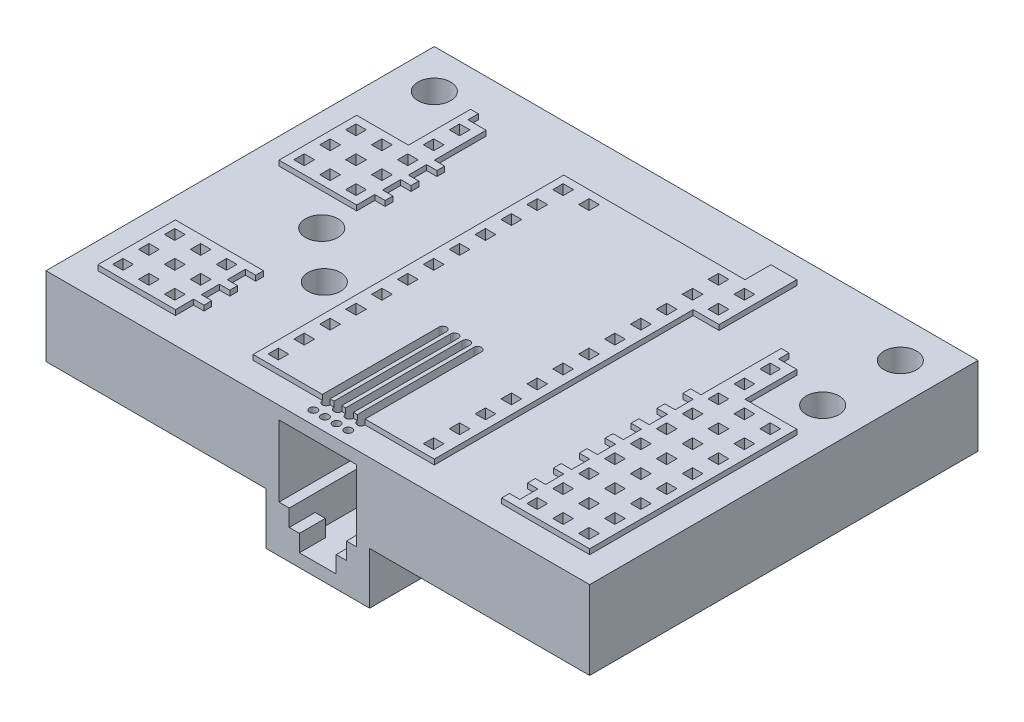
from build123d import *

# Parameters (mm, degrees)
SKETCH1_W             = 53.34
SKETCH1_H             = 38.1
SKETCH1_R             = 1.599999975
BREADBOARD_DEPTH      = 8.2296
SKETCH7_W             = 12.7
SKETCH7_H             = 2.032
CUT_EXTRUDE5_DEPTH    = 7.1628
LPATTERN4_COUNT       = 10
LPATTERN4_PITCH       = 2.54
LPATTERN4_COUNT_DIR2  = 2
LPATTERN4_PITCH_DIR2  = 25.4
SKETCH8_W             = 2.032
SKETCH8_H             = 12.7
CUT_EXTRUDE6_DEPTH    = 7.1628
LPATTERN5_COUNT       = 2
LPATTERN5_PITCH       = 12.7
LPATTERN5_COUNT_DIR2  = 2
LPATTERN5_PITCH_DIR2  = 2.54
SKETCH9_W             = 1.905
SKETCH9_H             = 20.32
CUT_EXTRUDE7_DEPTH    = 7.1628
LPATTERN6_COUNT       = 2
LPATTERN6_PITCH       = 2.54
SKETCH10_W            = 1.016
SKETCH10_H            = 1.016
CUT_EXTRUDE8_DEPTH    = 34.548429231
LPATTERN8_COUNT       = 12
LPATTERN8_PITCH       = 2.54
LPATTERN8_COUNT_DIR2  = 19
LPATTERN8_PITCH_DIR2  = 2.54
SKETCH12_W            = 12.7
SKETCH12_H            = 2.032
CUT_EXTRUDE9_DEPTH    = 7.1628
LPATTERN9_COUNT       = 2
LPATTERN9_PITCH       = 2.54
SKETCH47_W            = 10.16
SKETCH47_H            = 12.7
BOSS_EXTRUDE5_DEPTH   = 5.08
CUT_EXTRUDE33_DEPTH   = 10.9982
SKETCH57_W            = 5.6134
SKETCH57_H            = 9.7282
CUT_EXTRUDE34_DEPTH   = 1.651
SKETCH59_W            = 0.762
SKETCH59_H            = 4.064
CUT_EXTRUDE35_DEPTH   = 5.08
LPATTERN25_COUNT      = 4
LPATTERN25_PITCH      = 1.143
SKETCH62_R            = 0.381
CUT_EXTRUDE37_DEPTH   = 7.62
LPATTERN27_COUNT      = 4
LPATTERN27_PITCH      = 1.143
LPATTERN27_COUNT_DIR2 = 2
LPATTERN27_PITCH_DIR2 = 12.7
CUT_EXTRUDE38_DEPTH   = 1.27
LPATTERN28_COUNT      = 4
LPATTERN28_PITCH      = 1.143
SKETCH66_W            = 5.6134
SKETCH66_H            = 3.175
CUT_EXTRUDE41_DEPTH   = 0.508
SKETCH68_W            = 5.08
SKETCH68_H            = 2.032
CUT_EXTRUDE43_DEPTH   = 7.1628
TRACING_DEPTH         = 1.5748
SKETCH80_W            = 5.08
SKETCH80_H            = 2.032
CUT_EXTRUDE52_DEPTH   = 7.1628
SKETCH77_W            = 2.032
SKETCH77_H            = 1.27
CUT_EXTRUDE51_DEPTH   = 1.5748
LPATTERN32_COUNT      = 2
LPATTERN32_PITCH      = 2.54
LPATTERN32_COUNT_DIR2 = 2
LPATTERN32_PITCH_DIR2 = 26.67
SKETCH81_W            = 1.905
SKETCH81_H            = 1.27
CUT_EXTRUDE53_DEPTH   = 1.5748
LPATTERN33_COUNT      = 2
LPATTERN33_PITCH      = 2.54
LPATTERN33_COUNT_DIR2 = 2
LPATTERN33_PITCH_DIR2 = 21.59
SKETCH85_W            = 2.032
SKETCH85_H            = 2.032
CUT_EXTRUDE57_DEPTH   = 7.1628
LPATTERN34_COUNT      = 4
LPATTERN34_PITCH      = 2.54
SKETCH86_W            = 1.27
SKETCH86_H            = 2.032
CUT_EXTRUDE58_DEPTH   = 1.5748
LPATTERN35_COUNT      = 12
LPATTERN35_PITCH      = 2.54
LPATTERN35_COUNT_DIR2 = 2
LPATTERN35_PITCH_DIR2 = 11.43
SKETCH88_W            = 5.08
SKETCH88_H            = 2.032
CUT_EXTRUDE59_DEPTH   = 7.1628
LPATTERN36_COUNT      = 2
LPATTERN36_PITCH      = 2.54
SKETCH89_W            = 53.34
SKETCH89_H            = 38.1
CUT_EXTRUDE60_DEPTH   = 0.508


with BuildPart() as part:
    # Sketch1 → breadboard (new body)
    with BuildSketch(Plane(origin=(0, 0, 0), x_dir=(1, 0, 0), z_dir=(0, 1, 0))):
        Rectangle(SKETCH1_W, SKETCH1_H)
        with Locations(Location((-22.86, 15.24, 0), (0, 0, 270))):
            Circle(SKETCH1_R, mode=Mode.SUBTRACT)
        with Locations(Location((22.86, 15.24, 0), (0, 0, 270))):
            Circle(SKETCH1_R, mode=Mode.SUBTRACT)
        with Locations(Location((22.86, 7.62, 0), (0, 0, 270))):
            Circle(SKETCH1_R, mode=Mode.SUBTRACT)
        with Locations(Location((-16.764, -1.905, 0), (0, 0, 270))):
            Circle(SKETCH1_R, mode=Mode.SUBTRACT)
        with Locations(Location((-12.065, -6.35, 0), (0, 0, 270))):
            Circle(SKETCH1_R, mode=Mode.SUBTRACT)
    extrude(amount=BREADBOARD_DEPTH)

    # Sketch7 → Cut-Extrude5 (cut)
    with BuildSketch(Plane.XZ):
        with Locations((12.7, 15.24)):
            Rectangle(SKETCH7_W, SKETCH7_H)
    cut_extrude5 = extrude(amount=-CUT_EXTRUDE5_DEPTH, mode=Mode.SUBTRACT)

    # LPattern4: Cut-Extrude5 10 × 2, 4 skipped
    with Locations(*[(-j * LPATTERN4_PITCH_DIR2, 0, -i * LPATTERN4_PITCH) for i in range(LPATTERN4_COUNT) for j in range(LPATTERN4_COUNT_DIR2) if (i, j) not in ((0, 0), (3, 1), (4, 1), (5, 1), (6, 1))]):
        add(cut_extrude5, mode=Mode.SUBTRACT)

    # Sketch8 → Cut-Extrude6 (cut)
    with BuildSketch(Plane.XZ):
        with Locations((-22.86, 10.16)):
            Rectangle(SKETCH8_W, SKETCH8_H)
    cut_extrude6 = extrude(amount=-CUT_EXTRUDE6_DEPTH, mode=Mode.SUBTRACT)

    # LPattern5: Cut-Extrude6 2 × 2
    with Locations(*[(j * LPATTERN5_PITCH_DIR2, 0, -i * LPATTERN5_PITCH) for i in range(LPATTERN5_COUNT) for j in range(LPATTERN5_COUNT_DIR2) if (i, j) != (0, 0)]):
        add(cut_extrude6, mode=Mode.SUBTRACT)

    # Sketch9 → Cut-Extrude7 (cut)
    with BuildSketch(Plane.XZ):
        with Locations((22.86, 6.35)):
            Rectangle(SKETCH9_W, SKETCH9_H)
    cut_extrude7 = extrude(amount=-CUT_EXTRUDE7_DEPTH, mode=Mode.SUBTRACT)

    # LPattern6: Cut-Extrude7 ×2
    with Locations(*[(-i * LPATTERN6_PITCH, 0, 0) for i in range(1, LPATTERN6_COUNT)]):
        add(cut_extrude7, mode=Mode.SUBTRACT)

    # Sketch10 → Cut-Extrude8 (cut, through all)
    with BuildSketch(Plane.XZ.offset(-7.1628)):
        with Locations((-22.9235, 15.24)):
            Rectangle(SKETCH10_W, SKETCH10_H)
    cut_extrude8 = extrude(amount=-CUT_EXTRUDE8_DEPTH, mode=Mode.SUBTRACT)

    # LPattern8: Cut-Extrude8 12 × 19, 155 skipped
    with Locations(*[(j * LPATTERN8_PITCH_DIR2, 0, -i * LPATTERN8_PITCH) for i in range(LPATTERN8_COUNT) for j in range(LPATTERN8_COUNT_DIR2) if (i, j) not in ((0, 0), (0, 3), (0, 4), (0, 5), (0, 7), (0, 8), (0, 9), (0, 10), (0, 11), (0, 13), (0, 14), (0, 15), (1, 3), (1, 4), (1, 5), (1, 7), (1, 8), (1, 9), (1, 10), (1, 11), (1, 13), (1, 14), (1, 15), (2, 3), (2, 4), (2, 5), (2, 7), (2, 8), (2, 9), (2, 10), (2, 11), (2, 13), (2, 14), (2, 15), (3, 0), (3, 1), (3, 2), (3, 3), (3, 4), (3, 5), (3, 7), (3, 8), (3, 9), (3, 10), (3, 11), (3, 13), (3, 14), (3, 15), (4, 0), (4, 1), (4, 2), (4, 3), (4, 4), (4, 5), (4, 7), (4, 8), (4, 9), (4, 10), (4, 11), (4, 13), (4, 14), (4, 15), (5, 0), (5, 1), (5, 2), (5, 3), (5, 4), (5, 5), (5, 7), (5, 8), (5, 9), (5, 10), (5, 11), (5, 13), (5, 14), (5, 15), (6, 0), (6, 1), (6, 2), (6, 3), (6, 4), (6, 5), (6, 7), (6, 8), (6, 9), (6, 10), (6, 11), (6, 13), (6, 14), (6, 15), (7, 3), (7, 4), (7, 5), (7, 7), (7, 8), (7, 9), (7, 10), (7, 11), (7, 13), (7, 14), (7, 15), (8, 3), (8, 4), (8, 5), (8, 7), (8, 8), (8, 9), (8, 10), (8, 11), (8, 13), (8, 14), (8, 15), (8, 17), (8, 18), (9, 3), (9, 4), (9, 5), (9, 7), (9, 8), (9, 9), (9, 10), (9, 11), (9, 13), (9, 14), (9, 15), (9, 17), (9, 18), (10, 0), (10, 1), (10, 3), (10, 4), (10, 5), (10, 7), (10, 8), (10, 9), (10, 10), (10, 11), (10, 14), (10, 15), (10, 16), (10, 17), (10, 18), (11, 0), (11, 1), (11, 3), (11, 4), (11, 5), (11, 8), (11, 9), (11, 10), (11, 11), (11, 14), (11, 15), (11, 16), (11, 17), (11, 18))]):
        add(cut_extrude8, mode=Mode.SUBTRACT)

    # Sketch12 → Cut-Extrude9 (cut)
    with BuildSketch(Plane.XZ):
        with Locations((-12.7, -10.16)):
            Rectangle(SKETCH12_W, SKETCH12_H)
    cut_extrude9 = extrude(amount=-CUT_EXTRUDE9_DEPTH, mode=Mode.SUBTRACT)

    # LPattern9: Cut-Extrude9 ×2
    with Locations(*[(0, 0, -i * LPATTERN9_PITCH) for i in range(1, LPATTERN9_COUNT)]):
        add(cut_extrude9, mode=Mode.SUBTRACT)

    # Sketch47 → Boss-Extrude5 (add)
    with BuildSketch(Plane.XZ):
        with Locations((0, 12.7)):
            Rectangle(SKETCH47_W, SKETCH47_H)
    extrude(amount=BOSS_EXTRUDE5_DEPTH)

    # Sketch54 → Cut-Extrude33 (cut)
    with BuildSketch(Plane.XY.offset(19.05)):
        Polygon((-3.81, 6.477), (3.81, 6.477), (3.81, -0.508), (2.8067, -0.508), (2.8067, -2.159), (1.8034, -2.159), (1.8034, -3.81), (-1.8034, -3.81), (-1.8034, -2.159), (-2.8067, -2.159), (-2.8067, -0.508), (-3.81, -0.508), align=None)
    extrude(amount=-CUT_EXTRUDE33_DEPTH, mode=Mode.SUBTRACT)

    # Sketch57 → Cut-Extrude34 (cut)
    with BuildSketch(Plane(origin=(0, -2.159, 0), x_dir=(1, 0, 0), z_dir=(0, 1, 0))):
        with Locations((0, -11.6459)):
            Rectangle(SKETCH57_W, SKETCH57_H)
    extrude(amount=-CUT_EXTRUDE34_DEPTH, mode=Mode.SUBTRACT)

    # Sketch59 → Cut-Extrude35 (cut)
    with BuildSketch(Plane.XY.offset(8.0518)):
        with Locations((-1.7145, 4.445)):
            Rectangle(SKETCH59_W, SKETCH59_H)
    cut_extrude35 = extrude(amount=-CUT_EXTRUDE35_DEPTH, mode=Mode.SUBTRACT)

    # LPattern25: Cut-Extrude35 ×4
    with Locations(*[(i * LPATTERN25_PITCH, 0, 0) for i in range(1, LPATTERN25_COUNT)]):
        add(cut_extrude35, mode=Mode.SUBTRACT)

    # Sketch62 → Cut-Extrude37 (cut)
    with BuildSketch(Plane(origin=(0, 8.2296, 0), x_dir=(1, 0, 0), z_dir=(0, 1, 0))):
        with Locations(Location((-1.7145, -5.08, 0), (0, 0, 270))):
            Circle(SKETCH62_R)
    cut_extrude37 = extrude(amount=-CUT_EXTRUDE37_DEPTH, mode=Mode.SUBTRACT)

    # LPattern27: Cut-Extrude37 4 × 2
    with Locations(*[(i * LPATTERN27_PITCH, 0, j * LPATTERN27_PITCH_DIR2) for i in range(LPATTERN27_COUNT) for j in range(LPATTERN27_COUNT_DIR2) if (i, j) != (0, 0)]):
        add(cut_extrude37, mode=Mode.SUBTRACT)

    # Sketch63 → Cut-Extrude38 (cut)
    with BuildSketch(Plane(origin=(0, 8.2296, 0), x_dir=(1, 0, 0), z_dir=(0, 1, 0))):
        with BuildLine():
            Line((-2.0955, -16.51), (-2.0955, -5.08))
            ThreePointArc((-2.0955, -5.08), (-1.7145, -4.699), (-1.3335, -5.08))
            Line((-1.3335, -5.08), (-1.3335, -16.51))
            ThreePointArc((-1.3335, -16.51), (-1.7145, -16.891), (-2.0955, -16.51))
        make_face()
    cut_extrude38 = extrude(amount=-CUT_EXTRUDE38_DEPTH, mode=Mode.SUBTRACT)

    # LPattern28: Cut-Extrude38 ×4
    with Locations(*[(i * LPATTERN28_PITCH, 0, 0) for i in range(1, LPATTERN28_COUNT)]):
        add(cut_extrude38, mode=Mode.SUBTRACT)

    # Sketch66 → Cut-Extrude41 (cut)
    with BuildSketch(Plane.XY.offset(8.0518)):
        with Locations((0, -0.635)):
            Rectangle(SKETCH66_W, SKETCH66_H)
    extrude(amount=-CUT_EXTRUDE41_DEPTH, mode=Mode.SUBTRACT)

    # Sketch68 → Cut-Extrude43 (cut)
    with BuildSketch(Plane.XZ):
        with Locations((-3.4925, -12.7)):
            Rectangle(SKETCH68_W, SKETCH68_H)
    extrude(amount=-CUT_EXTRUDE43_DEPTH, mode=Mode.SUBTRACT)

    # Sketch69 → tracing (cut)
    with BuildSketch(Plane.XZ):
        with BuildLine():
            Line((-19.05, -13.97), (-19.05, -8.89))
            Line((-19.05, -8.89), (-23.876, -8.89))
            Line((-23.876, -8.89), (-23.876, -13.192186532))
            ThreePointArc((-23.876, -13.192186532), (-21.143121297, -13.730654606), (-20.959238048, -16.51))
            Line((-20.959238048, -16.51), (20.959238048, -16.51))
            ThreePointArc((20.959238048, -16.51), (21.120097775, -13.757253816), (23.8125, -13.161890342))
            Line((23.8125, -13.161890342), (23.8125, -9.698109658))
            ThreePointArc((23.8125, -9.698109658), (20.574, -7.62), (23.8125, -5.541890342))
            Line((23.8125, -5.541890342), (23.8125, -3.81))
            Line((23.8125, -3.81), (19.05, -3.81))
            Line((19.05, -3.81), (19.05, -8.636))
            Line((19.05, -8.636), (11.43, -8.636))
            Line((11.43, -8.636), (11.43, -13.97))
            Line((11.43, -13.97), (3.175, -13.97))
            Line((3.175, -13.97), (3.175, 6.096))
            Line((3.175, 6.096), (-6.35, 6.096))
            Line((-6.35, 6.096), (-6.35, 4.064))
            Line((-6.35, 4.064), (-3.175, 4.064))
            Line((-3.175, 4.064), (-3.175, -13.97))
            Line((-3.175, -13.97), (-19.05, -13.97))
        make_face()
    extrude(amount=-TRACING_DEPTH, mode=Mode.SUBTRACT)

    # Sketch80 → Cut-Extrude52 (cut)
    with BuildSketch(Plane.XZ):
        with Locations((-6.35, 5.08)):
            Rectangle(SKETCH80_W, SKETCH80_H)
    extrude(amount=-CUT_EXTRUDE52_DEPTH, mode=Mode.SUBTRACT)

    # Sketch77 → Cut-Extrude51 (cut)
    with BuildSketch(Plane.XZ):
        with Locations((-22.86, 17.145)):
            Rectangle(SKETCH77_W, SKETCH77_H)
    cut_extrude51 = extrude(amount=-CUT_EXTRUDE51_DEPTH, mode=Mode.SUBTRACT)

    # LPattern32: Cut-Extrude51 2 × 2
    with Locations(*[(i * LPATTERN32_PITCH, j * LPATTERN32_PITCH_DIR2, 0) for i in range(LPATTERN32_COUNT) for j in range(LPATTERN32_COUNT_DIR2) if (i, j) != (0, 0)]):
        add(cut_extrude51, mode=Mode.SUBTRACT)

    # Sketch81 → Cut-Extrude53 (cut)
    with BuildSketch(Plane.XZ):
        with Locations((20.32, 17.145)):
            Rectangle(SKETCH81_W, SKETCH81_H)
    cut_extrude53 = extrude(amount=-CUT_EXTRUDE53_DEPTH, mode=Mode.SUBTRACT)

    # LPattern33: Cut-Extrude53 2 × 2, 2 skipped
    with Locations(*[(i * LPATTERN33_PITCH, j * LPATTERN33_PITCH_DIR2, 0) for i in range(LPATTERN33_COUNT) for j in range(LPATTERN33_COUNT_DIR2) if (i, j) not in ((0, 0), (0, 1), (1, 1))]):
        add(cut_extrude53, mode=Mode.SUBTRACT)

    # Sketch85 → Cut-Extrude57 (cut)
    with BuildSketch(Plane.XZ):
        with Locations((-7.6835, 0)):
            Rectangle(SKETCH85_W, SKETCH85_H)
    cut_extrude57 = extrude(amount=-CUT_EXTRUDE57_DEPTH, mode=Mode.SUBTRACT)

    # LPattern34: Cut-Extrude57 ×4, 1 skipped
    with Locations(*[(0, 0, i * LPATTERN34_PITCH) for i in range(1, LPATTERN34_COUNT) if i not in (2,)]):
        add(cut_extrude57, mode=Mode.SUBTRACT)

    # Sketch86 → Cut-Extrude58 (cut)
    with BuildSketch(Plane.XZ):
        with Locations((-5.715, 15.24)):
            Rectangle(SKETCH86_W, SKETCH86_H)
    cut_extrude58 = extrude(amount=-CUT_EXTRUDE58_DEPTH, mode=Mode.SUBTRACT)

    # LPattern35: Cut-Extrude58 12 × 2, 5 skipped
    with Locations(*[(j * LPATTERN35_PITCH_DIR2, 0, -i * LPATTERN35_PITCH) for i in range(LPATTERN35_COUNT) for j in range(LPATTERN35_COUNT_DIR2) if (i, j) not in ((0, 0), (3, 0), (4, 0), (5, 0), (6, 0), (11, 0))]):
        add(cut_extrude58, mode=Mode.SUBTRACT)

    # Sketch88 → Cut-Extrude59 (cut)
    with BuildSketch(Plane.XZ):
        with Locations((8.89, -10.16)):
            Rectangle(SKETCH88_W, SKETCH88_H)
    cut_extrude59 = extrude(amount=-CUT_EXTRUDE59_DEPTH, mode=Mode.SUBTRACT)

    # LPattern36: Cut-Extrude59 ×2
    with Locations(*[(0, 0, -i * LPATTERN36_PITCH) for i in range(1, LPATTERN36_COUNT)]):
        add(cut_extrude59, mode=Mode.SUBTRACT)

    # Sketch89 → Cut-Extrude60 (cut)
    with BuildSketch(Plane(origin=(0, 8.2296, 0), x_dir=(1, 0, 0), z_dir=(0, 1, 0))):
        Rectangle(SKETCH89_W, SKETCH89_H)
        Polygon((-24.13, -8.89), (-15.494, -8.89), (-15.494, -9.652), (-16.51, -9.652), (-16.51, -11.43), (-15.494, -11.43), (-15.494, -12.192), (-16.51, -12.192), (-16.51, -13.97), (-15.494, -13.97), (-15.494, -14.732), (-16.51, -14.732), (-16.51, -16.51), (-24.13, -16.51), align=None, mode=Mode.SUBTRACT)
        Polygon((-16.51, 8.89), (-16.51, 13.97), (-18.288, 13.97), (-18.288, 14.986), (-19.05, 14.986), (-19.05, 8.89), (-24.13, 8.89), (-24.13, 1.27), (-16.51, 1.27), (-16.51, 3.048), (-15.494, 3.048), (-15.494, 3.81), (-16.51, 3.81), (-16.51, 5.588), (-15.494, 5.588), (-15.494, 6.35), (-16.51, 6.35), (-16.51, 8.128), (-15.494, 8.128), (-15.494, 8.89), align=None, mode=Mode.SUBTRACT)
        Polygon((-8.89, 13.97), (8.89, 13.97), (8.89, 16.51), (11.43, 16.51), (11.43, 8.89), (8.89, 8.89), (8.89, -16.51), (-8.89, -16.51), align=None, mode=Mode.SUBTRACT)
        Polygon((17.272, 8.89), (19.05, 8.89), (19.05, 3.81), (24.13, 3.81), (24.13, -16.51), (15.494, -16.51), (15.494, -15.748), (16.51, -15.748), (16.51, -13.97), (15.494, -13.97), (15.494, -13.208), (16.51, -13.208), (16.51, -11.43), (15.494, -11.43), (15.494, -10.668), (16.51, -10.668), (16.51, -8.89), (15.494, -8.89), (15.494, -8.128), (16.51, -8.128), (16.51, -6.35), (15.494, -6.35), (15.494, -5.588), (16.51, -5.588), (16.51, -3.81), (15.494, -3.81), (15.494, -3.048), (16.51, -3.048), (16.51, -1.27), (15.494, -1.27), (15.494, -0.508), (16.51, -0.508), (16.51, 1.27), (15.494, 1.27), (15.494, 2.032), (16.51, 2.032), (16.51, 9.906), (17.272, 9.906), align=None, mode=Mode.SUBTRACT)
    extrude(amount=-CUT_EXTRUDE60_DEPTH, mode=Mode.SUBTRACT)


solid = part.part
